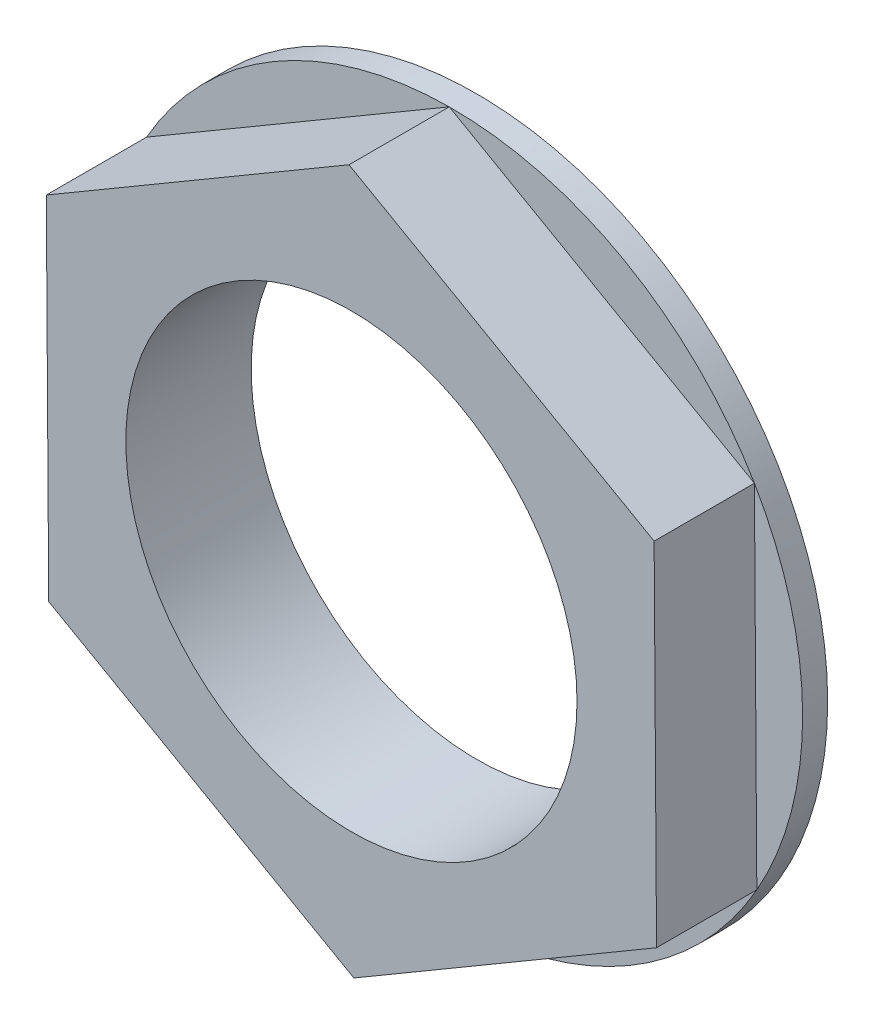
from build123d import *

# Parameters (mm, degrees)
ESQUISSE1_R        = 7
ESQUISSE1_R_2      = 4.5
BOSS_EXTRU_1_DEPTH = 0.5
ESQUISSE2_R        = 4.5
BOSS_EXTRU_2_DEPTH = 2


with BuildPart() as part:
    # Esquisse1 → Boss.-Extru.1 (new body)
    with BuildSketch(Plane.XY):
        Circle(ESQUISSE1_R)
        Circle(ESQUISSE1_R_2, mode=Mode.SUBTRACT)
    extrude(amount=BOSS_EXTRU_1_DEPTH)

    # Esquisse2 → Boss.-Extru.2 (add)
    with BuildSketch(Plane.XY.offset(0.5)):
        Polygon((6.086240364, -3.457987599), (6.037825289, 3.541844969), (-0.048415075, 6.999832568), (-6.086240364, 3.457987599), (-6.037825289, -3.541844969), (0.048415075, -6.999832568), align=None)
        Circle(ESQUISSE2_R, mode=Mode.SUBTRACT)
    extrude(amount=BOSS_EXTRU_2_DEPTH)


solid = part.part
